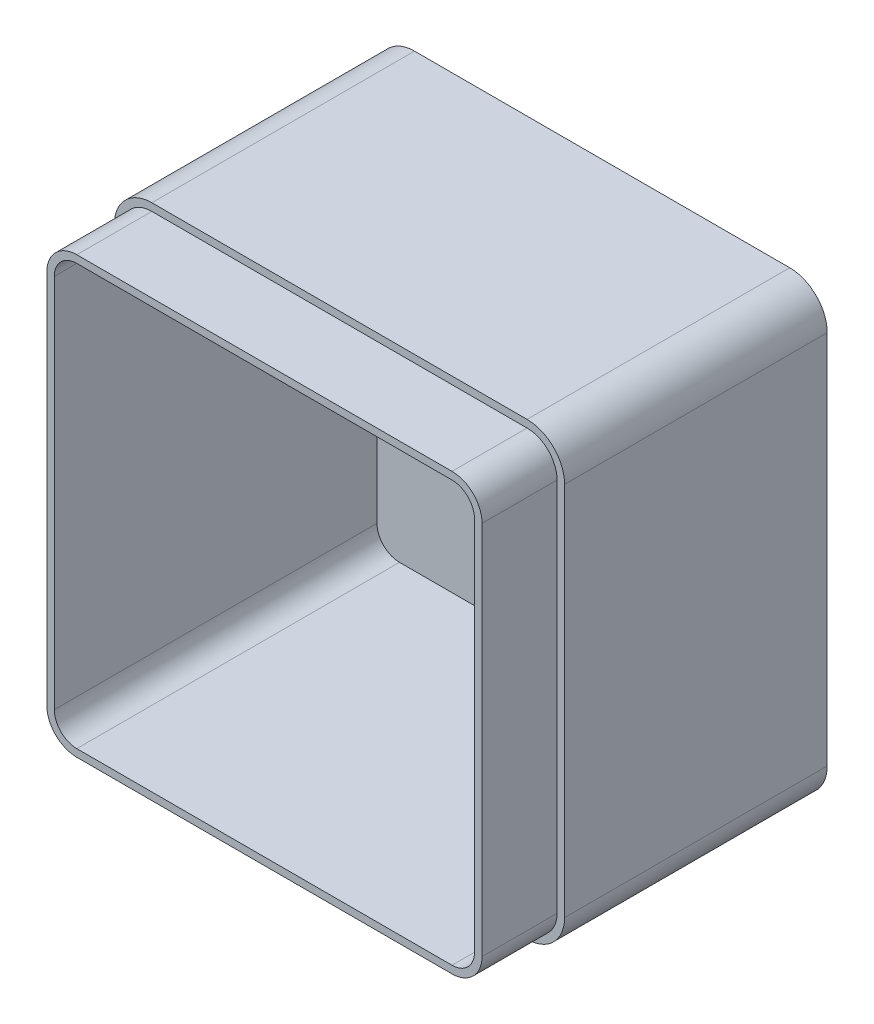
from build123d import *

# Parameters (mm, degrees)
SKETCH1_W           = 120
SKETCH1_H           = 120
BOSS_EXTRUDE1_DEPTH = 90
FILLET1_R           = 10
SHELL1_T            = -4
CUT_EXTRUDE1_DEPTH  = 20


with BuildPart() as part:
    # Sketch1 → Boss-Extrude1 (new body)
    with BuildSketch(Plane.XY):
        with Locations((60, 60)):
            Rectangle(SKETCH1_W, SKETCH1_H)
    extrude(amount=BOSS_EXTRUDE1_DEPTH)

    # Fillet1
    fillet1_edges = [part.edges().sort_by_distance(p)[0] for p in [
        (0, 120, 45),
        (120, 120, 45),
        (120, 0, 45),
        (0, 0, 45),
    ]]
    fillet(fillet1_edges, radius=FILLET1_R)

    # Shell1
    shell1_openings = [part.faces().sort_by_distance(p)[0] for p in [
        (60, 60, 90),
    ]]
    offset(amount=SHELL1_T, openings=shell1_openings, kind=Kind.INTERSECTION)

    # Sketch2 → Cut-Extrude1 (cut)
    with BuildSketch(Plane.XY.offset(90)):
        with BuildLine():
            Line((0, 110), (0, 10))
            ThreePointArc((0, 10), (2.928932188, 2.928932188), (10, 0))
            Line((10, 0), (110, 0))
            ThreePointArc((110, 0), (117.071067812, 2.928932188), (120, 10))
            Line((120, 10), (120, 110))
            ThreePointArc((120, 110), (117.071067812, 117.071067812), (110, 120))
            Line((110, 120), (10, 120))
            ThreePointArc((10, 120), (2.928932188, 117.071067812), (0, 110))
        make_face()
        with BuildLine():
            Line((2, 110), (2, 10))
            ThreePointArc((2, 10), (4.343145751, 4.343145751), (10, 2))
            Line((10, 2), (110, 2))
            ThreePointArc((110, 2), (115.656854249, 4.343145751), (118, 10))
            Line((118, 10), (118, 110))
            ThreePointArc((118, 110), (115.656854249, 115.656854249), (110, 118))
            Line((110, 118), (10, 118))
            ThreePointArc((10, 118), (4.343145751, 115.656854249), (2, 110))
        make_face(mode=Mode.SUBTRACT)
    extrude(amount=-CUT_EXTRUDE1_DEPTH, mode=Mode.SUBTRACT)


solid = part.part
